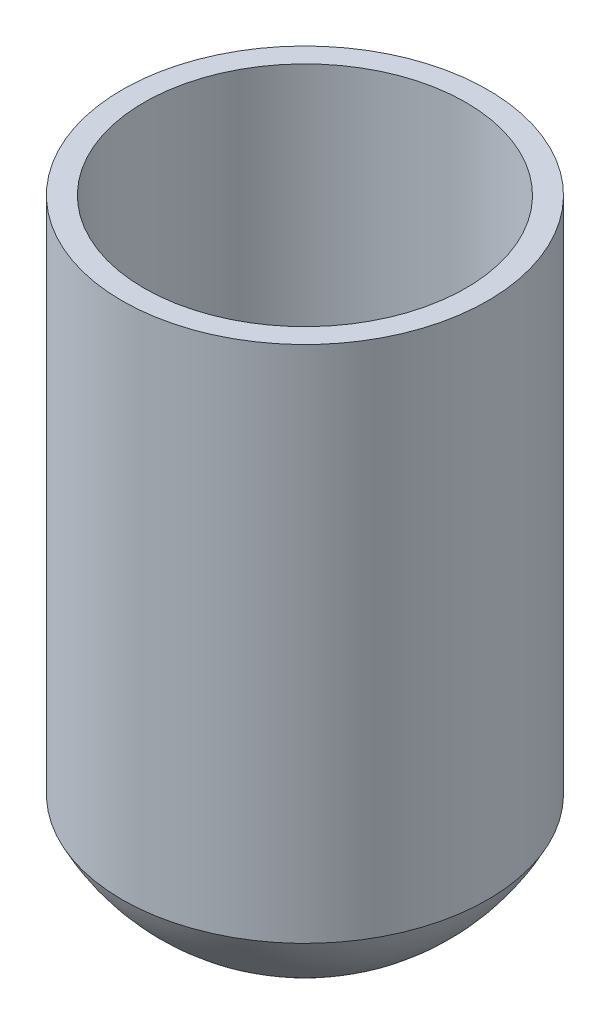
from build123d import *

# Parameters (mm, degrees)
SKETCH1_R           = 28.65374
SKETCH1_R_2         = 25.2222
BOSS_EXTRUDE1_DEPTH = 69.85
SKETCH1_3_R         = 28.65374
SKETCH1_3_R_2       = 25.2222
BOSS_EXTRUDE2_DEPTH = 11.43
DOME1_FACE_RADIUS   = 28.65374
DOME1_HEIGHT        = 17.78


with BuildPart() as part:
    # Sketch1 → Boss-Extrude1 (new body)
    with BuildSketch(Plane(origin=(0, 0, 0), x_dir=(1, 0, 0), z_dir=(0, 1, 0))):
        with Locations(Location((0, 0, 0), (0, 0, 270))):
            Circle(SKETCH1_R)
        with Locations(Location((0, 0, 0), (0, 0, 270))):
            Circle(SKETCH1_R_2, mode=Mode.SUBTRACT)
    extrude(amount=BOSS_EXTRUDE1_DEPTH)

    # Sketch1_3 → Boss-Extrude2 (add)
    with BuildSketch(Plane(origin=(0, 0, 0), x_dir=(1, 0, 0), z_dir=(0, 1, 0))):
        with Locations(Location((0, 0, 0), (0, 0, 270))):
            Circle(SKETCH1_3_R)
        with Locations(Location((0, 0, 0), (0, 0, 270))):
            Circle(SKETCH1_3_R_2, mode=Mode.SUBTRACT)
        with Locations(Location((0, 0, 0), (0, 0, 270))):
            Circle(SKETCH1_3_R_2)
    extrude(amount=-BOSS_EXTRUDE2_DEPTH)

    # Dome1: a dome of height H over a round flat face of radius A is a cap of a sphere of radius (A * A + H * H) / (2 * H)
    dome1_r = (DOME1_FACE_RADIUS * DOME1_FACE_RADIUS + DOME1_HEIGHT * DOME1_HEIGHT) / (2 * DOME1_HEIGHT)
    dome1_base = Plane((0, -11.43, 0), z_dir=(0, -1, 0))
    with Locations(dome1_base.offset(DOME1_HEIGHT - dome1_r)):
        dome1_ball = Sphere(dome1_r, mode=Mode.PRIVATE)
    add(split(dome1_ball, bisect_by=dome1_base, keep=Keep.TOP, mode=Mode.PRIVATE))


solid = part.part
